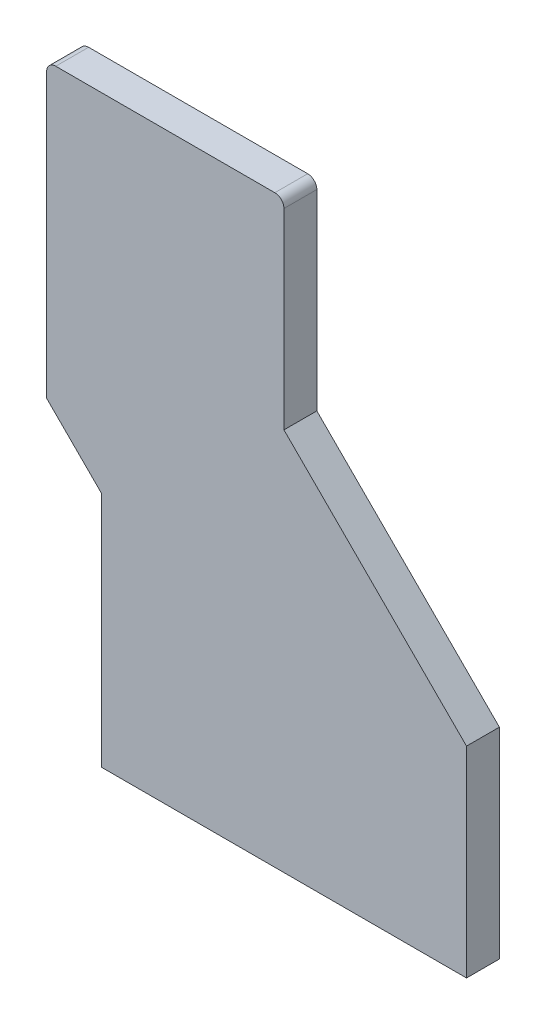
from build123d import *

# Parameters (mm, degrees)
BOSS_EXTRUDE1_DEPTH = 18


with BuildPart() as part:
    # Sketch1 → Boss-Extrude1 (new body)
    with BuildSketch(Plane.XY):
        with BuildLine():
            Line((4.070181983, 148.487708827), (4.070181983, 43.487708827))
            Line((4.070181983, 43.487708827), (104.070181983, -56.512291173))
            Line((104.070181983, -56.512291173), (104.070181983, -166.512291173))
            Line((104.070181983, -166.512291173), (-95.929818017, -166.512291173))
            Line((-95.929818017, -166.512291173), (-95.929818017, -36.512291173))
            Line((-95.929818017, -36.512291173), (-125.929818017, -6.512291173))
            Line((-125.929818017, -6.512291173), (-125.929818017, 148.487708827))
            ThreePointArc((-125.929818017, 148.487708827), (-124.465351923, 152.023242733), (-120.929818017, 153.487708827))
            Line((-120.929818017, 153.487708827), (-95.929818017, 153.487708827))
            Line((-95.929818017, 153.487708827), (-0.929818017, 153.487708827))
            ThreePointArc((-0.929818017, 153.487708827), (2.605715889, 152.023242733), (4.070181983, 148.487708827))
        make_face()
    extrude(amount=BOSS_EXTRUDE1_DEPTH)


solid = part.part
